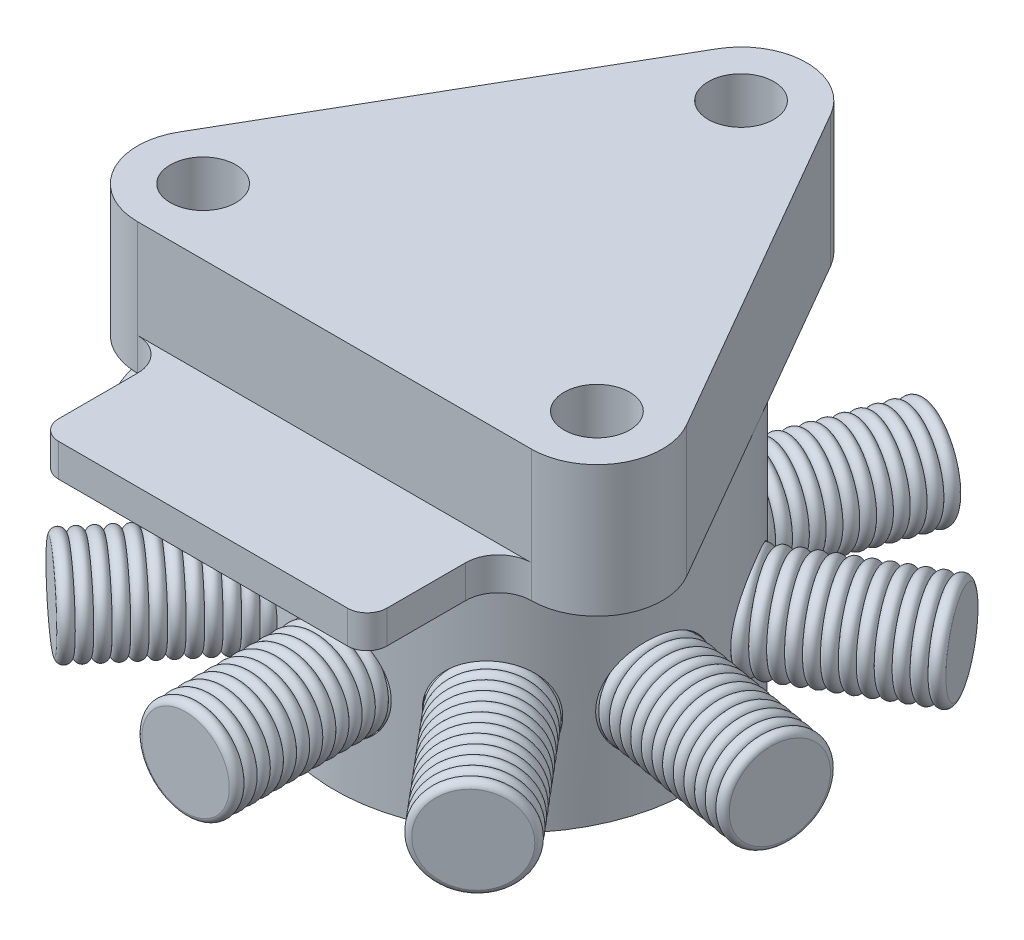
from build123d import *
from build123d.topology import SkipClean

# Parameters (mm, degrees)
ESBO_O1_R                = 0.5
RESSALTO_EXTRUS_O1_DEPTH = 2
RESSALTO_EXTRUS_O2_DEPTH = 0.5
ESBO_O3_R                = 2.732050808
RESSALTO_EXTRUS_O3_DEPTH = 4
ESBO_O5_R                = 0.75
RESSALTO_EXTRUS_O4_DEPTH = 5
PADR_OCIRCULAR1_COUNT    = 9


with BuildPart() as part:
    # Esboço1 → Ressalto-extrusão1 (new body)
    with BuildSketch(Plane(origin=(0, 0, 0), x_dir=(1, 0, 0), z_dir=(0, 1, 0))):
        with BuildLine():
            Line((0.866025404, 3.964101615), (3.866025404, -1.232050808))
            ThreePointArc((3.866025404, -1.232050808), (3.866025404, -2.232050808), (3, -2.732050808))
            Line((3, -2.732050808), (-3, -2.732050808))
            ThreePointArc((-3, -2.732050808), (-3.866025404, -2.232050808), (-3.866025404, -1.232050808))
            Line((-3.866025404, -1.232050808), (-0.866025404, 3.964101615))
            ThreePointArc((-0.866025404, 3.964101615), (0, 4.464101615), (0.866025404, 3.964101615))
        make_face()
        with Locations(Location((0, 3.464101615, 0), (0, 0, 270))):
            Circle(ESBO_O1_R, mode=Mode.SUBTRACT)
        with Locations(Location((3, -1.732050808, 0), (0, 0, 270))):
            Circle(ESBO_O1_R, mode=Mode.SUBTRACT)
        with Locations(Location((-3, -1.732050808, 0), (0, 0, 270))):
            Circle(ESBO_O1_R, mode=Mode.SUBTRACT)
    extrude(amount=RESSALTO_EXTRUS_O1_DEPTH)

    # Esboço2 → Ressalto-extrusão2 (add)
    with BuildSketch(Plane.XZ):
        with BuildLine():
            Line((-2.5, 3.232050808), (-2.5, 4.432050808))
            ThreePointArc((-2.5, 4.432050808), (-2.412132034, 4.644182842), (-2.2, 4.732050808))
            Line((-2.2, 4.732050808), (2.2, 4.732050808))
            ThreePointArc((2.2, 4.732050808), (2.412132034, 4.644182842), (2.5, 4.432050808))
            Line((2.5, 4.432050808), (2.5, 3.232050808))
            ThreePointArc((2.5, 3.232050808), (2.646446609, 2.878497417), (3, 2.732050808))
            Line((3, 2.732050808), (-3, 2.732050808))
            ThreePointArc((-3, 2.732050808), (-2.646446609, 2.878497417), (-2.5, 3.232050808))
        make_face()
    extrude(amount=-RESSALTO_EXTRUS_O2_DEPTH)

    # Esboço3 → Ressalto-extrusão3 (add)
    with BuildSketch(Plane(origin=(0, 0, 0), x_dir=(-1, 0, 0), z_dir=(0, -1, 0))):
        with Locations(Location((0, 0, 0), (0, 0, 30))):
            Circle(ESBO_O3_R)
    extrude(amount=RESSALTO_EXTRUS_O3_DEPTH)

    # Esboço5 → Ressalto-extrusão4 (add)
    with BuildSketch(Plane.XY):
        with Locations(Location((0, -2.5, 0), (0, 0, 270))):
            Circle(ESBO_O5_R)
    ressalto_extrus_o4 = extrude(amount=RESSALTO_EXTRUS_O4_DEPTH)

    # Esboço7 → Corte-Revolução1 (revolve, cut)
    with SkipClean():  # the faces are left unmerged after this step: merging them gives an invalid solid
        with BuildSketch(Plane(origin=(0, -2.5, 0), x_dir=(-1, 0, 0), z_dir=(0, -1, 0))):
            with BuildLine():
                Line((-0.666054689, -5), (-0.666054689, -5.087172646))
                Line((-0.666054689, -5.087172646), (-0.76, -5.087172646))
                Line((-0.76, -5.087172646), (-0.76, -1.909234169))
                Line((-0.76, -1.909234169), (-0.666054689, -1.909234169))
                Line((-0.666054689, -1.909234169), (-0.666054689, -2))
                ThreePointArc((-0.666054689, -2), (-0.75, -2.1), (-0.666054689, -2.2))
                ThreePointArc((-0.666054689, -2.2), (-0.75, -2.3), (-0.666054689, -2.4))
                ThreePointArc((-0.666054689, -2.4), (-0.75, -2.5), (-0.666054689, -2.6))
                ThreePointArc((-0.666054689, -2.6), (-0.75, -2.7), (-0.666054689, -2.8))
                ThreePointArc((-0.666054689, -2.8), (-0.75, -2.9), (-0.666054689, -3))
                ThreePointArc((-0.666054689, -3), (-0.75, -3.1), (-0.666054689, -3.2))
                ThreePointArc((-0.666054689, -3.2), (-0.75, -3.3), (-0.666054689, -3.4))
                ThreePointArc((-0.666054689, -3.4), (-0.75, -3.5), (-0.666054689, -3.6))
                ThreePointArc((-0.666054689, -3.6), (-0.75, -3.7), (-0.666054689, -3.8))
                ThreePointArc((-0.666054689, -3.8), (-0.75, -3.9), (-0.666054689, -4))
                ThreePointArc((-0.666054689, -4), (-0.75, -4.1), (-0.666054689, -4.2))
                ThreePointArc((-0.666054689, -4.2), (-0.75, -4.3), (-0.666054689, -4.4))
                ThreePointArc((-0.666054689, -4.4), (-0.75, -4.5), (-0.666054689, -4.6))
                ThreePointArc((-0.666054689, -4.6), (-0.75, -4.7), (-0.666054689, -4.8))
                ThreePointArc((-0.666054689, -4.8), (-0.75, -4.9), (-0.666054689, -5))
            make_face()
        corte_revolu_o1 = revolve(axis=Axis((0, -2.5, 5), (0, 0, -1)), mode=Mode.SUBTRACT)

    # PadrãoCircular1: Ressalto-extrusão4, Corte-Revolução1 ×9 about axis
    with SkipClean():  # the faces are left unmerged after this step: merging them gives an invalid solid
        padr_ocircular1_axis = Axis((0, 0, 0), (0, 1, 0))
        add([ressalto_extrus_o4.rotate(padr_ocircular1_axis, i * 360 / PADR_OCIRCULAR1_COUNT) for i in range(1, PADR_OCIRCULAR1_COUNT)])
        add([corte_revolu_o1.rotate(padr_ocircular1_axis, i * 360 / PADR_OCIRCULAR1_COUNT) for i in range(1, PADR_OCIRCULAR1_COUNT)], mode=Mode.SUBTRACT)


solid = part.part
